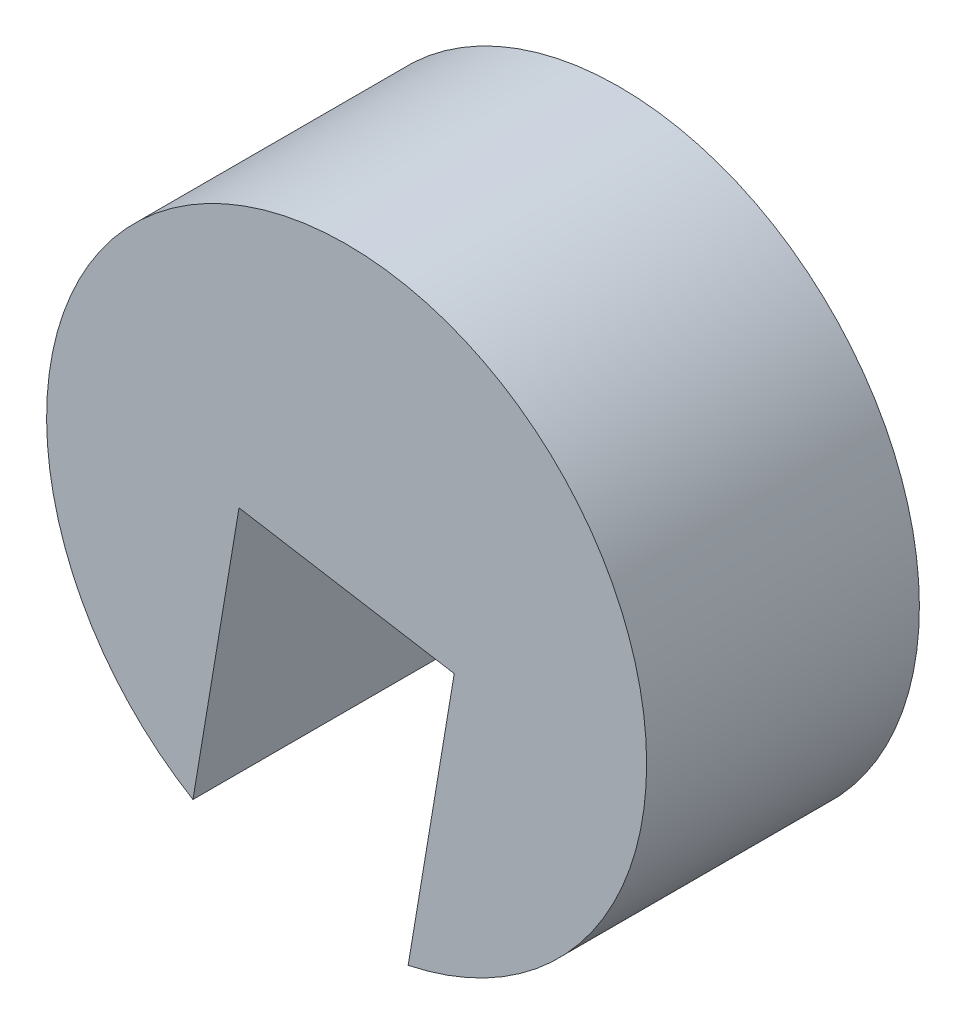
from build123d import *

# Parameters (mm, degrees)
SKETCH1_R           = 5.5
BOSS_EXTRUDE1_DEPTH = 5
CUT_EXTRUDE3_DEPTH  = 5


with BuildPart() as part:
    # Sketch1 → Boss-Extrude1 (new body)
    with BuildSketch(Plane.XY):
        Circle(SKETCH1_R)
    extrude(amount=BOSS_EXTRUDE1_DEPTH)

    # Sketch2 → Cut-Extrude3 (cut)
    with BuildSketch(Plane.XY.offset(5)):
        with BuildLine():
            Line((0, 0), (-1.972639316, 0.329687929))
            Line((-1.972639316, 0.329687929), (-2.817213309, -4.723696558))
            add(Edge.make_bspline(
                [(-2.817213309, -4.723696558), (-2.331717092, -5.013604459), (-1.497847825, -5.349651617), (-0.517167494, -5.488823483), (0.280656275, -5.510097286), (0.757829967, -5.460753651), (1.128065322, -5.383072415)],
                knots=[0, 0, 0, 0, 0.414681005, 0.650712608, 0.722388742, 1, 1, 1, 1], degree=3))
            Line((1.128065322, -5.383072415), (1.972639316, -0.329687929))
            Line((1.972639316, -0.329687929), (0, 0))
        make_face()
    extrude(amount=-CUT_EXTRUDE3_DEPTH, mode=Mode.SUBTRACT)


with BuildPart() as cut_extrude3_kept_piece:
    # of the separate pieces the step leaves, the one the design keeps (cut_extrude3_pieces_kept)
    add(part.part.solids().sort_by_distance((1.128065322, -5.383072415, 0))[0])


solid = cut_extrude3_kept_piece.part
